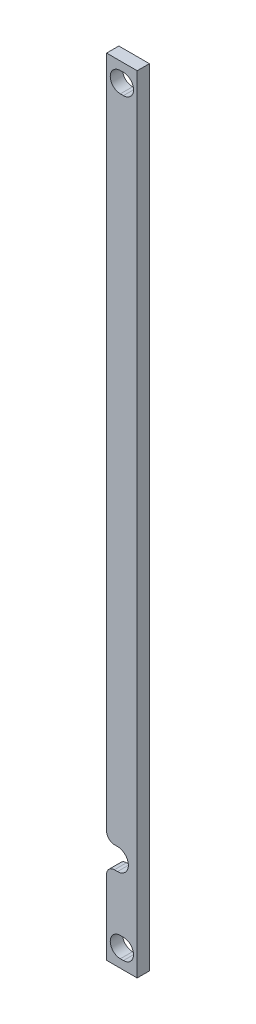
from build123d import *

# Parameters (mm, degrees)
SKETCH1_W           = 5
SKETCH1_H           = 128.5
BOSS_EXTRUDE1_DEPTH = 2
CUT_EXTRUDE1_DEPTH  = 2.54
FILLET1_R           = 1.27


with BuildPart() as part:
    # Sketch1 → Boss-Extrude1 (new body)
    with BuildSketch(Plane.XY):
        Rectangle(SKETCH1_W, SKETCH1_H)
        with BuildLine():
            Line((-0.254, -59.6), (0.254, -59.6))
            ThreePointArc((0.254, -59.6), (1.904, -61.25), (0.254, -62.9))
            Line((0.254, -62.9), (-0.254, -62.9))
            ThreePointArc((-0.254, -62.9), (-1.904, -61.25), (-0.254, -59.6))
        make_face(mode=Mode.SUBTRACT)
        with BuildLine():
            Line((-0.254, 62.9), (0.254, 62.9))
            ThreePointArc((0.254, 62.9), (1.904, 61.25), (0.254, 59.6))
            Line((0.254, 59.6), (-0.254, 59.6))
            ThreePointArc((-0.254, 59.6), (-1.904, 61.25), (-0.254, 62.9))
        make_face(mode=Mode.SUBTRACT)
    extrude(amount=BOSS_EXTRUDE1_DEPTH)

    # Sketch2 → Cut-Extrude1 (cut)
    with BuildSketch(Plane.XY.offset(2)):
        with BuildLine():
            Line((-0.722, -47.232), (-2.5, -47.232))
            Line((-2.5, -47.232), (-2.5, -50.788))
            Line((-2.5, -50.788), (-0.722, -50.788))
            ThreePointArc((-0.722, -50.788), (1.056, -49.01), (-0.722, -47.232))
        make_face()
    extrude(amount=-CUT_EXTRUDE1_DEPTH, mode=Mode.SUBTRACT)

    # Fillet1
    fillet1_edges = [part.edges().sort_by_distance(p)[0] for p in [
        (-2.5, -47.232, 1),
        (-2.5, -50.788, 1),
    ]]
    fillet(fillet1_edges, radius=FILLET1_R)


solid = part.part
